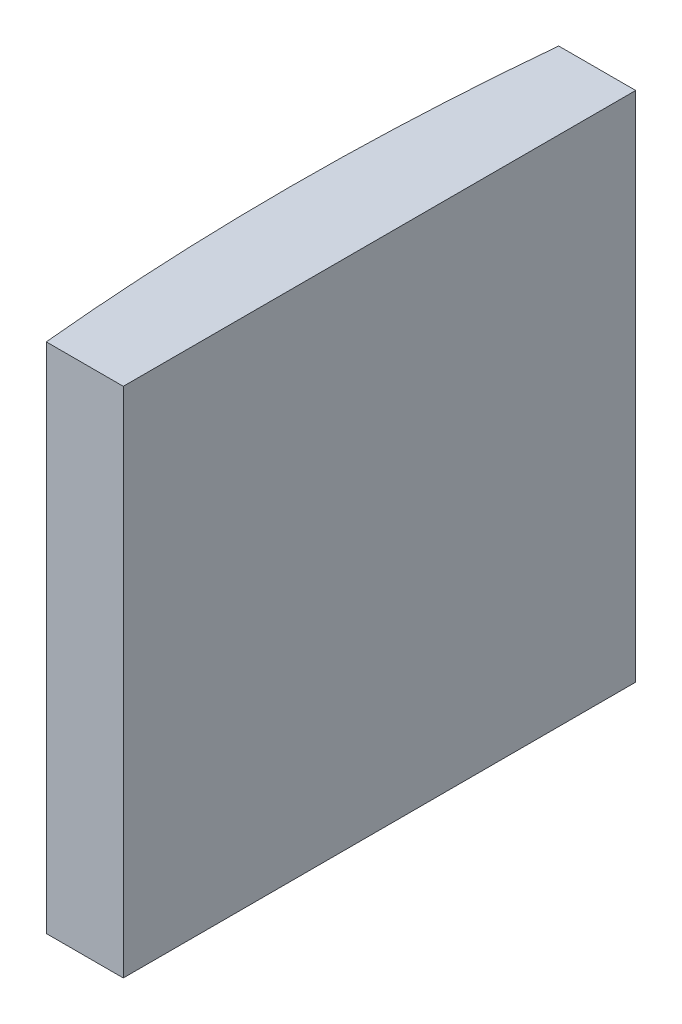
from build123d import *

# Parameters (mm, degrees)
EXTRUDE_1_DEPTH = 20


with BuildPart() as part:
    # 草图1 → 凸台-拉伸1 (new body)
    with BuildSketch(Plane(origin=(0, 0, 0), x_dir=(1, 0, 0), z_dir=(0, 1, 0))):
        with BuildLine():
            Line((-98.560100649, 10), (-95.554795665, 10))
            Line((-95.554795665, 10), (-95.554795665, -10))
            Line((-95.554795665, -10), (-98.560100649, -10))
            ThreePointArc((-98.560100649, -10), (-99.044795665, 0), (-98.560100649, 10))
        make_face()
    extrude(amount=EXTRUDE_1_DEPTH)


solid = part.part
